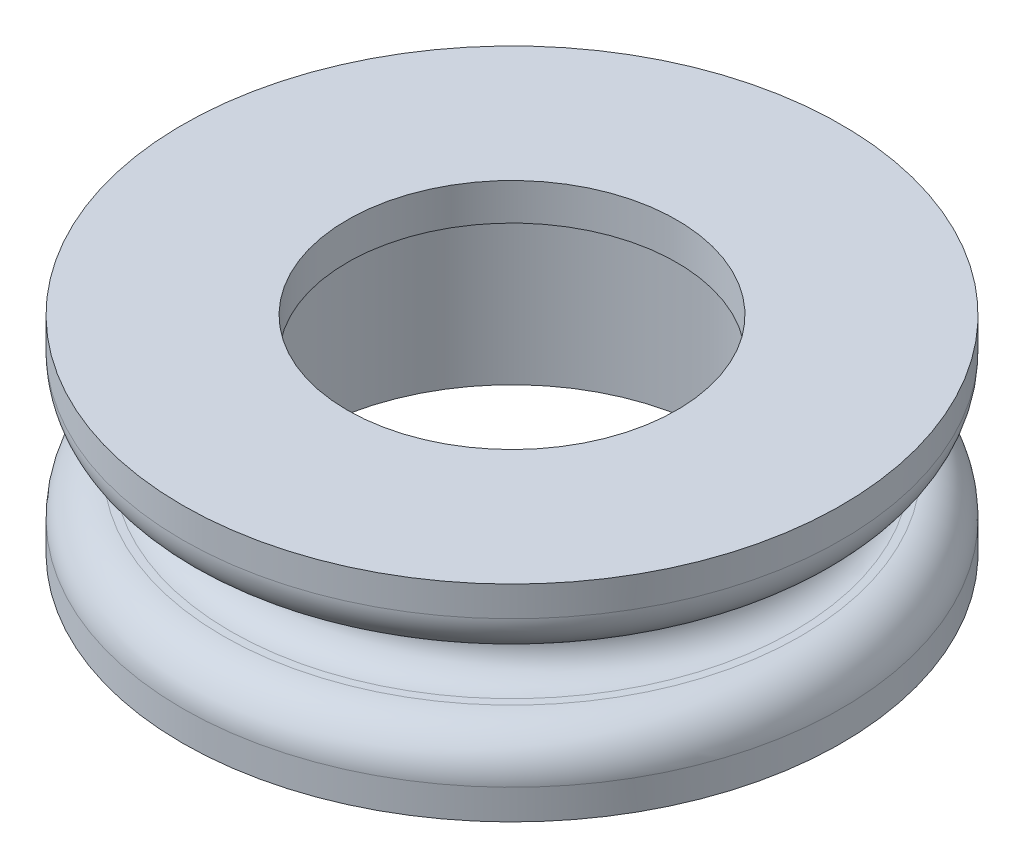
from build123d import *

# Parameters (mm, degrees)
FILLET5_R = 2.286
FILLET6_R = 1.6002


with BuildPart() as part:
    # Sketch2 → Revolve1 (revolve)
    with BuildSketch(Plane(origin=(0, 0, 0), x_dir=(0, 0, -1), z_dir=(1, 0, 0))):
        Polygon((8.89, 5.55752), (8.89, 3.5687), (11.1125, 3.5687), (11.1125, -5.55752), (17.78, -5.55752), (17.78, -1.7399), (13.639699492, -1.57734), (13.639699492, 1.57734), (17.78, 1.7399), (17.78, 5.55752), align=None)
    revolve(axis=Axis((0, 16.043148, 0), (0, -1, 0)))

    # Fillet5
    fillet5_edges = [part.edges().sort_by_distance(p)[0] for p in [
        (0, 1.7399, 17.78),
        (0, -1.7399, 17.78),
    ]]
    fillet(fillet5_edges, radius=FILLET5_R)

    # Fillet6
    fillet6_edges = [part.edges().sort_by_distance(p)[0] for p in [
        (0, 1.57734, 13.639699492),
        (0, -1.57734, 13.639699492),
    ]]
    fillet(fillet6_edges, radius=FILLET6_R)


solid = part.part
